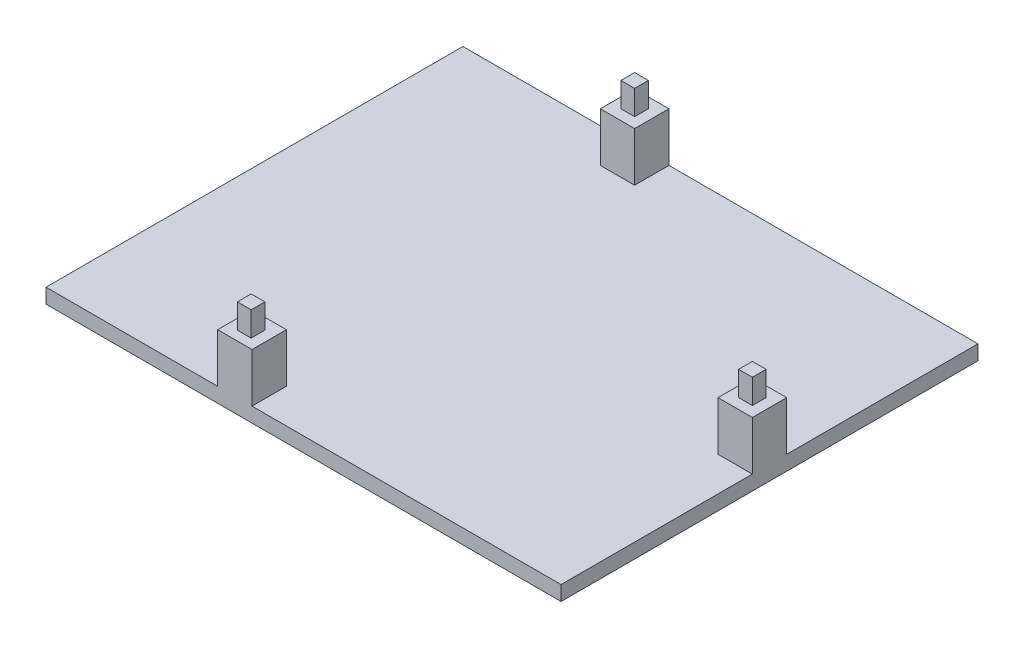
from build123d import *

# Parameters (mm, degrees)
SKETCH1_W            = 105
SKETCH1_H            = 85
BOSS_EXTRUDE1_DEPTH  = 3
SKETCH2_W            = 2.8
SKETCH2_H            = 2.8
BOSS_EXTRUDE2_DEPTH  = 15
SKETCH2_7_W          = 7
SKETCH2_7_H          = 7
SKETCH2_7_W_2        = 2.8
SKETCH2_7_H_2        = 2.8
BOSS_EXTRUDE3_DEPTH  = 10
SKETCH4_W            = 2.8
SKETCH4_H            = 2.8
BOSS_EXTRUDE7_DEPTH  = 15
SKETCH8_W            = 7
SKETCH8_H            = 7
SKETCH8_W_2          = 2.8
SKETCH8_H_2          = 2.8
BOSS_EXTRUDE8_DEPTH  = 10
SKETCH9_W            = 2.8
SKETCH9_H            = 2.8
BOSS_EXTRUDE9_DEPTH  = 15
SKETCH10_W           = 7
SKETCH10_H           = 7
SKETCH10_W_2         = 2.8
SKETCH10_H_2         = 2.8
BOSS_EXTRUDE10_DEPTH = 10


with BuildPart() as part:
    # Sketch1 → Boss-Extrude1 (new body)
    with BuildSketch(Plane(origin=(0, 0, 0), x_dir=(1, 0, 0), z_dir=(0, 1, 0))):
        with Locations((-10.290249703, -17.251010702)):
            Rectangle(SKETCH1_W, SKETCH1_H)
    extrude(amount=BOSS_EXTRUDE1_DEPTH)

    # Sketch2 → Boss-Extrude2 (add)
    with BuildSketch(Plane(origin=(0, 3, 0), x_dir=(1, 0, 0), z_dir=(0, 1, 0))):
        with Locations((-24.290249703, -56.430856566)):
            Rectangle(SKETCH2_W, SKETCH2_H)
    extrude(amount=BOSS_EXTRUDE2_DEPTH)

    # Sketch2_7 → Boss-Extrude3 (add)
    with BuildSketch(Plane(origin=(0, 3, 0), x_dir=(1, 0, 0), z_dir=(0, 1, 0))):
        with Locations((-24.290249703, -56.251010702)):
            Rectangle(SKETCH2_7_W, SKETCH2_7_H)
        with Locations((-24.290249703, -56.430856566)):
            Rectangle(SKETCH2_7_W_2, SKETCH2_7_H_2, mode=Mode.SUBTRACT)
    extrude(amount=BOSS_EXTRUDE3_DEPTH)

    # Sketch4 → Boss-Extrude7 (add)
    with BuildSketch(Plane(origin=(0, 3, 0), x_dir=(1, 0, 0), z_dir=(0, 1, 0))):
        with Locations((-24.290249703, 21.748989298)):
            Rectangle(SKETCH4_W, SKETCH4_H)
    extrude(amount=BOSS_EXTRUDE7_DEPTH)

    # Sketch8 → Boss-Extrude8 (add)
    with BuildSketch(Plane(origin=(0, 3, 0), x_dir=(1, 0, 0), z_dir=(0, 1, 0))):
        with Locations((-24.290249703, 21.748989298)):
            Rectangle(SKETCH8_W, SKETCH8_H)
        with Locations((-24.290249703, 21.748989298)):
            Rectangle(SKETCH8_W_2, SKETCH8_H_2, mode=Mode.SUBTRACT)
    extrude(amount=BOSS_EXTRUDE8_DEPTH)

    # Sketch9 → Boss-Extrude9 (add)
    with BuildSketch(Plane(origin=(0, 3, 0), x_dir=(1, 0, 0), z_dir=(0, 1, 0))):
        with Locations((38.709750297, -17.251010702)):
            Rectangle(SKETCH9_W, SKETCH9_H)
    extrude(amount=BOSS_EXTRUDE9_DEPTH)

    # Sketch10 → Boss-Extrude10 (add)
    with BuildSketch(Plane(origin=(0, 3, 0), x_dir=(1, 0, 0), z_dir=(0, 1, 0))):
        with Locations((38.709750297, -17.251010702)):
            Rectangle(SKETCH10_W, SKETCH10_H)
        with Locations((38.709750297, -17.251010702)):
            Rectangle(SKETCH10_W_2, SKETCH10_H_2, mode=Mode.SUBTRACT)
    extrude(amount=BOSS_EXTRUDE10_DEPTH)


solid = part.part
